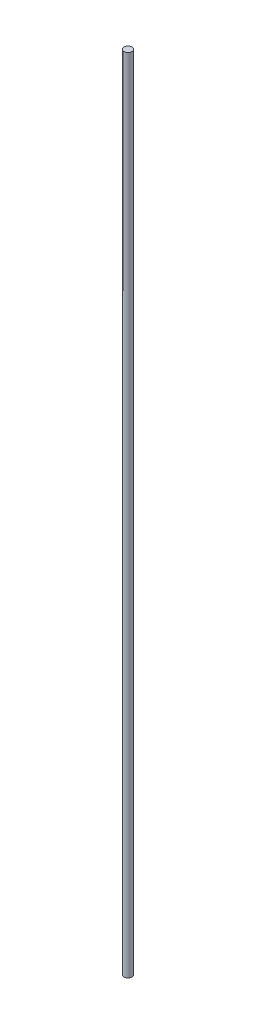
from build123d import *

# Parameters (mm, degrees)
SKETCH3_R           = 12
BOSS_EXTRUDE1_DEPTH = 2400


with BuildPart() as part:
    # Sketch3 → Boss-Extrude1 (new body)
    with BuildSketch(Plane(origin=(0, 0, 0), x_dir=(1, 0, 0), z_dir=(0, 1, 0))):
        Circle(SKETCH3_R)
    extrude(amount=BOSS_EXTRUDE1_DEPTH)


solid = part.part
